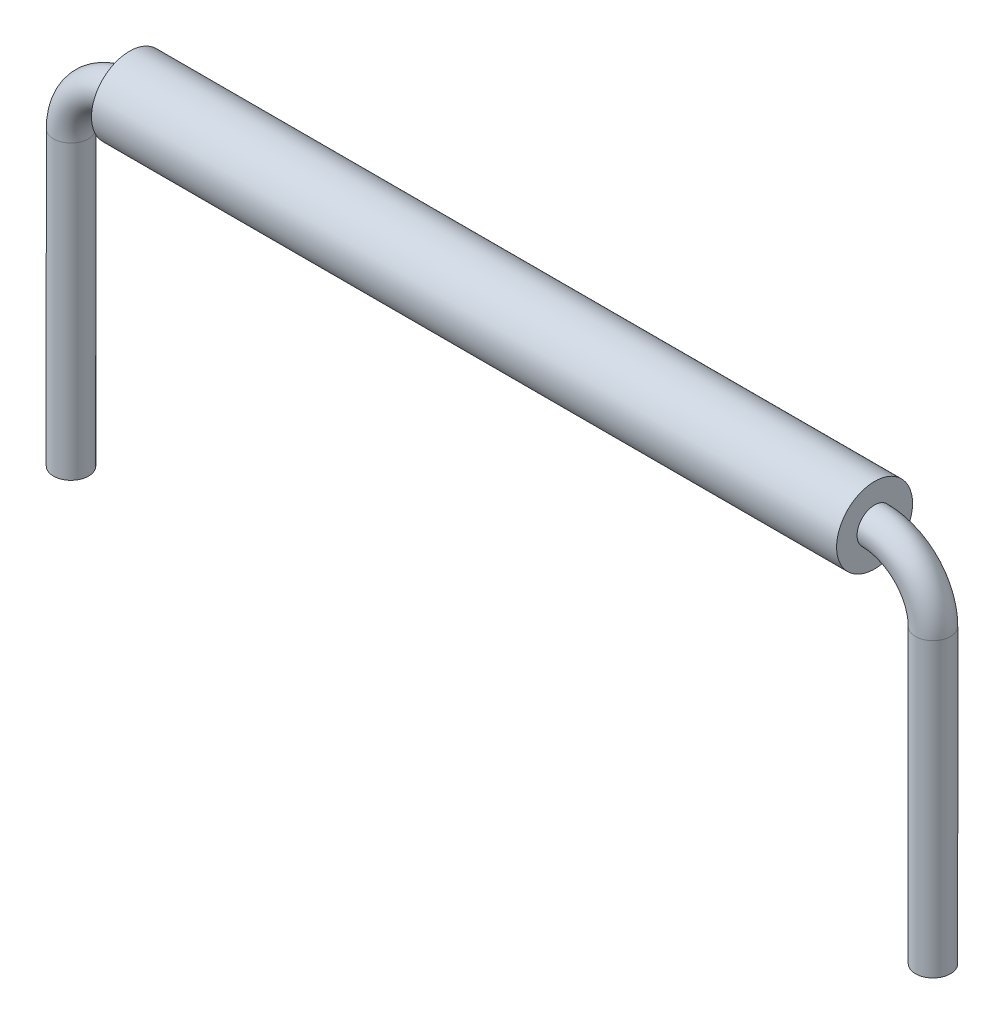
from build123d import *

# Parameters (mm, degrees)
SKETCH2_R                = 0.3
SKETCH3_R                = 0.65
SKETCH3_R_2              = 0.3
BOSS_EXTRUDE1_DEPTH      = 6.3775
BOSS_EXTRUDE1_DEPTH_BACK = 6.3775


with BuildPart() as part:
    # Sweep1: sweep along a path in Sketch1
    with BuildLine(Plane.XY) as sweep1_path:
        Line((-7.3775, -6), (-7.3775, -1))
        ThreePointArc((-7.3775, -1), (-7.084606781, -0.292893219), (-6.3775, 0))
        Line((-6.3775, 0), (6.3775, 0))
        ThreePointArc((6.3775, 0), (7.084606781, -0.292893219), (7.3775, -1))
        Line((7.3775, -1), (7.3775, -6))
    # Sketch2 → Sweep1 (sweep)
    with BuildSketch(Plane(origin=(0, 0, 0), x_dir=(0, 0, -1), z_dir=(1, 0, 0))):
        Circle(SKETCH2_R)
    sweep(path=sweep1_path.line)


with BuildPart() as body_2:
    # Sketch3 → Boss-Extrude1 (new body, two sides)
    with BuildSketch(Plane(origin=(0, 0, 0), x_dir=(0, 0, -1), z_dir=(1, 0, 0))) as boss_extrude1_sk:
        Circle(SKETCH3_R)
        Circle(SKETCH3_R_2, mode=Mode.SUBTRACT)
    extrude(amount=BOSS_EXTRUDE1_DEPTH)
    extrude(boss_extrude1_sk.sketch, amount=-BOSS_EXTRUDE1_DEPTH_BACK)


solid = Compound([part.part, body_2.part])
